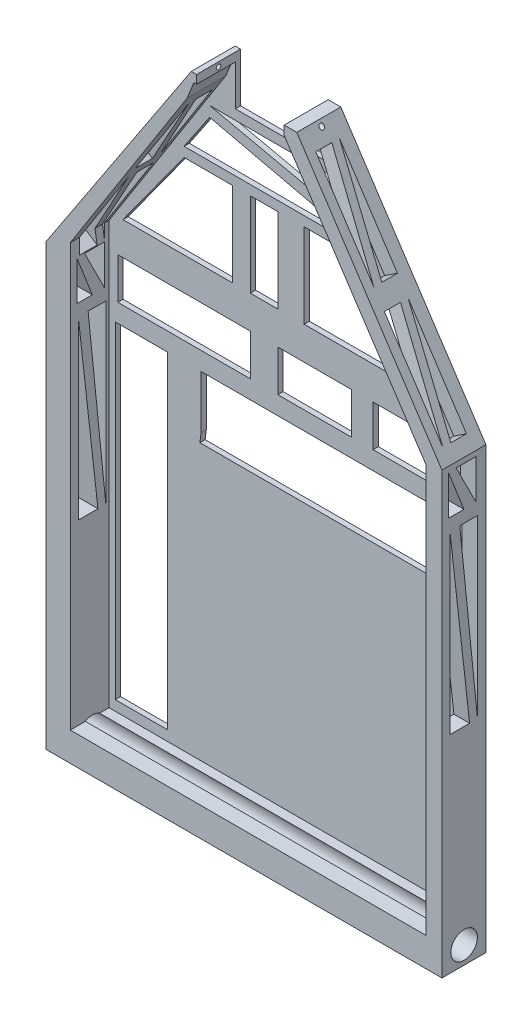
from build123d import *

# Parameters (mm, degrees)
BOSS_EXTRUDE2_DEPTH      = 6.35
CUT_EXTRUDE1_DEPTH       = 5.588
CUT_EXTRUDE3_DEPTH       = 58.15
CUT_EXTRUDE4_DEPTH       = 58.15
CUT_EXTRUDE5_DEPTH       = 5.588
CUT_EXTRUDE6_DEPTH       = 5.588
SKETCH9_W                = 5.834897671
SKETCH9_H                = 6.35
CUT_EXTRUDE7_DEPTH       = 5.588
SKETCH14_W               = 35.347523306
SKETCH14_H               = 7.62
SKETCH14_W_2             = 7.5222908
SKETCH14_H_2             = 47.221578267
CUT_EXTRUDE15_DEPTH      = 1.762
CUT_EXTRUDE16_DEPTH      = 1.762
SKETCH16_W               = 19.137714492
SKETCH16_H               = 5.958224415
SKETCH16_W_2             = 10.658290022
SKETCH16_W_3             = 11.400659267
SKETCH16_W_4             = 3.957226521
SKETCH16_H_2             = 12.183905404
CUT_EXTRUDE18_DEPTH      = 1.762
SKETCH24_W               = 3.80459217
SKETCH24_H               = 5.588
CUT_EXTRUDE24_DEPTH      = 7.35
CUT_EXTRUDE25_DEPTH      = 11.684
SKETCH26_W               = 3.014165169
SKETCH26_H               = 5.588
CUT_EXTRUDE26_DEPTH      = 11.684
SKETCH28_R               = 0.333403054
CUT_EXTRUDE27_DEPTH      = 35.377669607
CUT_EXTRUDE27_DEPTH_BACK = 23.772330393
SKETCH29_R               = 1.924206534
CUT_EXTRUDE28_DEPTH      = 58.15


with BuildPart() as part:
    # Sketch1 → Boss-Extrude2 (new body)
    with BuildSketch(Plane.XY):
        Polygon((0, 0), (57.15, 0), (57.15, 63.5), (36.195, 95.25), (28.575, 95.25), (20.955, 95.25), (0, 63.5), align=None)
    extrude(amount=BOSS_EXTRUDE2_DEPTH)

    # Sketch2 → Cut-Extrude1 (cut)
    with BuildSketch(Plane.XY.offset(6.35)):
        Polygon((20.364000747, 91.616461208), (21.329039406, 94.01667417), (34.339089661, 94.01667417), (54.882736024, 62.961525589), (54.882736024, 4.173376451), (3.496365447, 4.173376451), (3.496365447, 65.109859062), align=None)
    extrude(amount=-CUT_EXTRUDE1_DEPTH, mode=Mode.SUBTRACT)

    # Sketch5 → Cut-Extrude3 (cut, through all)
    with BuildSketch(Plane(origin=(57.15, 0, 0), x_dir=(0, 0, -1), z_dir=(1, 0, 0))):
        Polygon((-5.197962118, 29.849901792), (-2.356915502, 29.849901792), (-5.197962118, 55.260698225), align=None)
        Polygon((-1.216346756, 29.849901792), (-1.216346756, 55.260698225), (-3.77743881, 55.260698225), align=None)
    extrude(amount=-CUT_EXTRUDE3_DEPTH, mode=Mode.SUBTRACT)

    # Sketch6 → Cut-Extrude4 (cut, through all)
    with BuildSketch(Plane(origin=(57.15, 0, 0), x_dir=(0, 0, -1), z_dir=(1, 0, 0))):
        Polygon((-5.412954005, 57.003118273), (-3.170845056, 57.003118273), (-5.412954005, 62.734975907), align=None)
        Polygon((-4.291899531, 62.734975907), (-1.412268241, 62.734975907), (-1.412268241, 57.003118273), align=None)
    extrude(amount=-CUT_EXTRUDE4_DEPTH, mode=Mode.SUBTRACT)

    # Sketch7 → Cut-Extrude5 (cut)
    with BuildSketch(Plane(origin=(69.002507662, 45.541655057, 0), x_dir=(0, 0, -1), z_dir=(0.834609407, 0.550842208, 0))):
        Polygon((-5.125103363, 23.517131124), (-5.125103363, 38.818816904), (-2.804754482, 38.818816904), align=None)
        Polygon((-3.964928922, 23.517131124), (-1.710138277, 23.517131124), (-1.710138277, 38.818816904), align=None)
        Polygon((-5.125103363, 41.600750711), (-5.125103363, 56.813922895), (-2.804754482, 56.813922895), align=None)
        Polygon((-3.964928922, 41.600750711), (-1.710138277, 41.600750711), (-1.710138277, 56.813922895), align=None)
    extrude(amount=-CUT_EXTRUDE5_DEPTH, mode=Mode.SUBTRACT)

    # Sketch8 → Cut-Extrude6 (cut)
    with BuildSketch(Plane(origin=(-29.193368626, 19.267623293, 0), x_dir=(0, 0, 1), z_dir=(-0.834609407, 0.550842208, 0))):
        Polygon((5.014666305, 54.401267981), (2.473695685, 54.401267981), (5.014666305, 69.338714317), align=None)
        Polygon((1.401941454, 54.401267981), (1.401941454, 69.338714317), (3.744180995, 69.338714317), align=None)
        Polygon((5.014666305, 71.297820033), (2.573061224, 71.297820033), (4.755204833, 85.214267299), align=None)
        Polygon((1.401941454, 71.297820033), (1.401941454, 85.214267299), (3.793863765, 85.214267299), align=None)
    extrude(amount=-CUT_EXTRUDE6_DEPTH, mode=Mode.SUBTRACT)

    # Sketch9 → Cut-Extrude7 (cut)
    with BuildSketch(Plane(origin=(0, 95.25, 0), x_dir=(1, 0, 0), z_dir=(0, 1, 0))):
        with Locations((28.446055603, -3.175)):
            Rectangle(SKETCH9_W, SKETCH9_H)
    extrude(amount=-CUT_EXTRUDE7_DEPTH, mode=Mode.SUBTRACT)

    # Sketch14 → Cut-Extrude15 (cut, through all)
    with BuildSketch(Plane.XY.offset(0.762)):
        with Locations((34.456497677, 49.047397654)):
            Rectangle(SKETCH14_W, SKETCH14_H)
        with Locations((8.166161846, 29.246608521)):
            Rectangle(SKETCH14_W_2, SKETCH14_H_2)
    extrude(amount=-CUT_EXTRUDE15_DEPTH, mode=Mode.SUBTRACT)

    # Sketch15 → Cut-Extrude16 (cut, through all)
    with BuildSketch(Plane.XY.offset(0.762)):
        Polygon((16.621939644, 43.865236106), (52.148781332, 43.865236106), (52.13025933, 45.237397654), (16.782736024, 45.237397654), align=None)
    extrude(amount=-CUT_EXTRUDE16_DEPTH, mode=Mode.SUBTRACT)

    # Sketch16 → Cut-Extrude18 (cut, through all)
    with BuildSketch(Plane.XY.offset(0.762)):
        with Locations((14.332787326, 58.472819058)):
            Rectangle(SKETCH16_W, SKETCH16_H)
        with Locations((33.188016104, 58.472819058)):
            Rectangle(SKETCH16_W_2, SKETCH16_H)
        with Locations((47.320715601, 58.472819058)):
            Rectangle(SKETCH16_W_3, SKETCH16_H)
        Polygon((49.98907512, 66.19967542), (41.620385968, 78.383580824), (31.6768604, 78.383580824), (31.6768604, 66.19967542), align=None)
        with Locations((25.880257832, 72.291628122)):
            Rectangle(SKETCH16_W_4, SKETCH16_H_2)
        Polygon((5.507881152, 66.19967542), (14.332787326, 78.383580824), (21.316943171, 78.383580824), (21.316943171, 66.19967542), align=None)
        Polygon((18.022227631, 85.25088415), (14.332787326, 79.783581396), (41.620385968, 79.783581396), align=None)
        Polygon((18.022227631, 86.733909891), (37.577072812, 86.733909891), (41.620385968, 81.514612422), align=None)
    extrude(amount=-CUT_EXTRUDE18_DEPTH, mode=Mode.SUBTRACT)

    # Sketch24 → Cut-Extrude24 (cut, through all)
    with BuildSketch(Plane(origin=(0, 0, 0), x_dir=(-1, 0, 0), z_dir=(0, 0, -1))):
        with Locations((-23.626310682, 92.456)):
            Rectangle(SKETCH24_W, SKETCH24_H)
    extrude(amount=-CUT_EXTRUDE24_DEPTH, mode=Mode.SUBTRACT)

    # Sketch25 → Cut-Extrude25 (cut)
    with BuildSketch(Plane(origin=(0, 0, 0), x_dir=(-1, 0, 0), z_dir=(0, 0, -1))):
        Polygon((-21.724014597, 89.662), (-21.724014597, 88.165353891), (-34.377669607, 88.165353891), (-34.377669607, 89.662), (-31.363504438, 89.662), align=None)
    extrude(amount=-CUT_EXTRUDE25_DEPTH, mode=Mode.SUBTRACT)

    # Sketch26 → Cut-Extrude26 (cut)
    with BuildSketch(Plane(origin=(0, 0, 0), x_dir=(-1, 0, 0), z_dir=(0, 0, -1))):
        with Locations((-32.870587023, 92.456)):
            Rectangle(SKETCH26_W, SKETCH26_H)
    extrude(amount=-CUT_EXTRUDE26_DEPTH, mode=Mode.SUBTRACT)

    # Sketch28 → Cut-Extrude27 (cut, two sides)
    with BuildSketch(Plane.ZY.offset(-34.377669607)) as cut_extrude27_sk:
        with Locations(Location((3.175, 94.604177073, 0), (0, 0, 90))):  # turned: the seam where the file's is
            Circle(SKETCH28_R)
    extrude(amount=CUT_EXTRUDE27_DEPTH, mode=Mode.SUBTRACT)
    extrude(cut_extrude27_sk.sketch, amount=-CUT_EXTRUDE27_DEPTH_BACK, mode=Mode.SUBTRACT)

    # Sketch29 → Cut-Extrude28 (cut, through all)
    with BuildSketch(Plane(origin=(57.15, 0, 0), x_dir=(0, 0, -1), z_dir=(1, 0, 0))):
        with Locations((-3.151671904, 2.54588231)):
            Circle(SKETCH29_R)
    extrude(amount=-CUT_EXTRUDE28_DEPTH, mode=Mode.SUBTRACT)


solid = part.part
